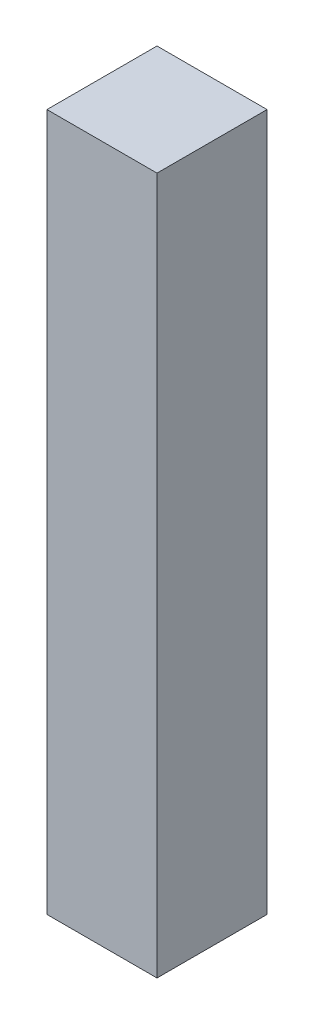
from build123d import *

# Parameters (mm, degrees)
SKETCH1_W           = 30
SKETCH1_H           = 30
BOSS_EXTRUDE1_DEPTH = 190


with BuildPart() as part:
    # Sketch1 → Boss-Extrude1 (new body)
    with BuildSketch(Plane(origin=(0, 0, 0), x_dir=(1, 0, 0), z_dir=(0, 1, 0))):
        Rectangle(SKETCH1_W, SKETCH1_H)
    extrude(amount=BOSS_EXTRUDE1_DEPTH)


solid = part.part
